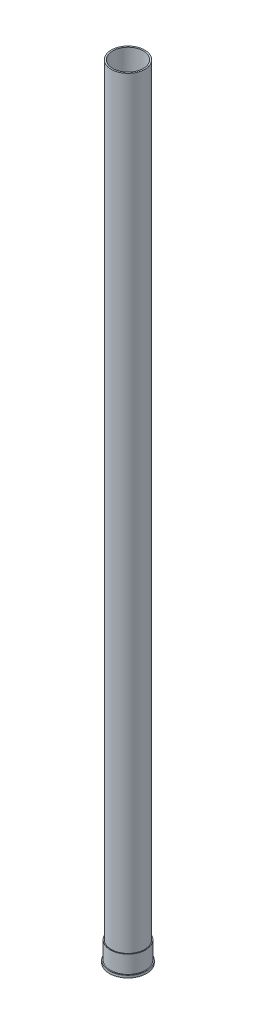
from build123d import *

# Parameters (mm, degrees)
SKETCH1_R           = 15
SKETCH1_R_2         = 13.462
BOSS_EXTRUDE1_DEPTH = 15
SKETCH4_R           = 14.2875
SKETCH4_R_2         = 13.0429
BOSS_EXTRUDE5_DEPTH = 650
BOSS_EXTRUDE6_START = -2
SKETCH1_4_R         = 15.875
SKETCH1_4_R_2       = 13.462
BOSS_EXTRUDE6_DEPTH = 2


with BuildPart() as part:
    # Sketch1 → Boss-Extrude1 (new body)
    with BuildSketch(Plane(origin=(0, 0, 0), x_dir=(1, 0, 0), z_dir=(0, 1, 0))):
        Circle(SKETCH1_R)
        Circle(SKETCH1_R_2, mode=Mode.SUBTRACT)
    extrude(amount=BOSS_EXTRUDE1_DEPTH)

    # Sketch4 → Boss-Extrude5 (add)
    with BuildSketch(Plane(origin=(0, 15, 0), x_dir=(1, 0, 0), z_dir=(0, 1, 0))):
        Circle(SKETCH4_R)
        Circle(SKETCH4_R_2, mode=Mode.SUBTRACT)
    extrude(amount=BOSS_EXTRUDE5_DEPTH)

    # Sketch1_4 → Boss-Extrude6 (add)
    with BuildSketch(Plane(origin=(0, 0, 0), x_dir=(1, 0, 0), z_dir=(0, 1, 0)).offset(BOSS_EXTRUDE6_START)):
        Circle(SKETCH1_4_R)
        Circle(SKETCH1_4_R_2, mode=Mode.SUBTRACT)
    extrude(amount=BOSS_EXTRUDE6_DEPTH)


solid = part.part
